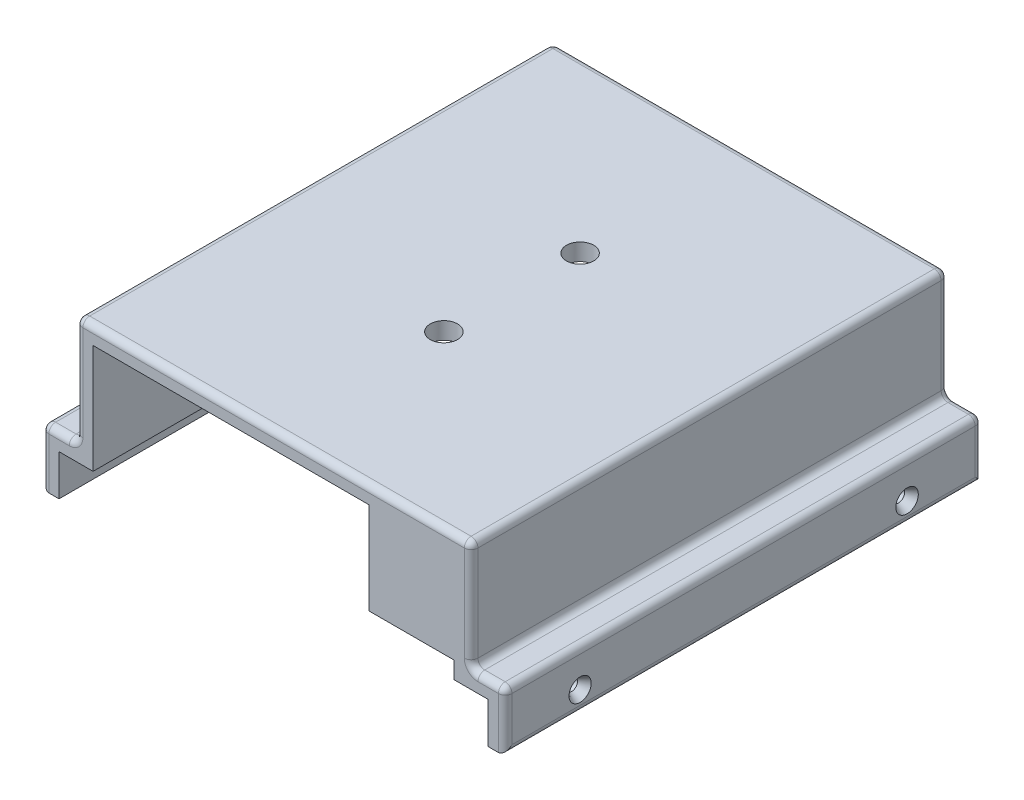
from build123d import *

# Parameters (mm, degrees)
BOSS_EXTRUDE1_DEPTH   = 140
SKETCH4_W             = 25
SKETCH4_H             = 27
BOSS_EXTRUDE2_DEPTH   = 5
SKETCH5_W             = 25
SKETCH5_H             = 27
BOSS_EXTRUDE3_DEPTH   = 5
FILLET1_R             = 2
SKETCH6_R             = 1.75
SKETCH6_R_2           = 1.8
CUT_EXTRUDE1_DEPTH    = 137
CHAMFER1_SIZE         = 1.5
CHAMFER1_SIZE2        = 2.5
CHAMFER2_SIZE         = 2.5
CHAMFER2_SIZE2        = 1.5
CHAMFER2_PART_2_SIZE  = 2.5
CHAMFER2_PART_2_SIZE2 = 1.5
SKETCH8_R             = 4
CUT_EXTRUDE2_DEPTH    = 50


with BuildPart() as part:
    # Sketch3 → Boss-Extrude1 (new body)
    with BuildSketch(Plane.XY):
        Polygon((-58, 0), (58, 0), (58, -32), (68, -32), (68, -49), (63, -49), (63, -37), (53, -37), (53, -5), (-53, -5), (-53, -37), (-63, -37), (-63, -49), (-68, -49), (-68, -32), (-58, -32), align=None)
    extrude(amount=-BOSS_EXTRUDE1_DEPTH)

    # Sketch4 → Boss-Extrude2 (add)
    with BuildSketch(Plane.XY):
        with Locations((40.5, -18.5)):
            Rectangle(SKETCH4_W, SKETCH4_H)
    extrude(amount=-BOSS_EXTRUDE2_DEPTH)

    # Sketch5 → Boss-Extrude3 (add)
    with BuildSketch(Plane(origin=(0, 0, -140), x_dir=(-1, 0, 0), z_dir=(0, 0, -1))):
        with Locations((40.5, -18.5)):
            Rectangle(SKETCH5_W, SKETCH5_H)
    extrude(amount=-BOSS_EXTRUDE3_DEPTH)

    # Fillet1
    fillet1_edges = [part.edges().sort_by_distance(p)[0] for p in [
        (-58, -16, -140),
        (63, -32, 0),
        (68, -40.5, 0),
        (-63, -32, -140),
        (-68, -40.5, 0),
        (-63, -32, 0),
        (-68, -40.5, -140),
        (-58, -16, 0),
        (0, 0, 0),
        (58, -16, 0),
        (58, -32, -70),
        (68, -32, -70),
        (68, -49, -70),
        (-68, -49, -70),
        (-68, -32, -70),
        (-58, -32, -70),
        (-58, 0, -70),
        (58, 0, -70),
        (58, -16, -140),
        (68, -40.5, -140),
        (63, -32, -140),
        (0, 0, -140),
    ]]
    fillet(fillet1_edges, radius=FILLET1_R)

    # Sketch6 → Cut-Extrude1 (cut, through all)
    with BuildSketch(Plane(origin=(68, 0, 0), x_dir=(0, 0, -1), z_dir=(1, 0, 0))):
        with Locations((22, -43)):
            Circle(SKETCH6_R)
        with Locations((118, -43)):
            Circle(SKETCH6_R_2)
    extrude(amount=-CUT_EXTRUDE1_DEPTH, mode=Mode.SUBTRACT)

    # Chamfer1
    chamfer1_edges = [part.edges().sort_by_distance(p)[0] for p in [
        (68, -43, -20.25),
        (68, -43, -116.2),
    ]]
    chamfer1_side = [part.faces().sort_by_distance(p)[0] for p in [
        (68, -40.471685324, -69.984689184),
    ]]
    chamfer(chamfer1_edges, length=CHAMFER1_SIZE, length2=CHAMFER1_SIZE2, reference=chamfer1_side[0])

    # Chamfer2
    chamfer2_edges = [part.edges().sort_by_distance(p)[0] for p in [
        (-68, -43, -20.25),
    ]]
    chamfer2_side = [part.faces().sort_by_distance(p)[0] for p in [
        (-65.5, -43, -20.25),
    ]]
    chamfer(chamfer2_edges, length=CHAMFER2_SIZE, length2=CHAMFER2_SIZE2, reference=chamfer2_side[0])

    # Chamfer2 part 2
    chamfer2_part_2_edges = [part.edges().sort_by_distance(p)[0] for p in [
        (-68, -43, -116.2),
    ]]
    chamfer2_part_2_side = [part.faces().sort_by_distance(p)[0] for p in [
        (-65.5, -43, -116.2),
    ]]
    chamfer(chamfer2_part_2_edges, length=CHAMFER2_PART_2_SIZE, length2=CHAMFER2_PART_2_SIZE2, reference=chamfer2_part_2_side[0])

    # Sketch8 → Cut-Extrude2 (cut, through all)
    with BuildSketch(Plane(origin=(0, 0, 0), x_dir=(1, 0, 0), z_dir=(0, 1, 0))):
        with Locations((0, 90)):
            Circle(SKETCH8_R)
        with Locations((0, 50)):
            Circle(SKETCH8_R)
    extrude(amount=-CUT_EXTRUDE2_DEPTH, mode=Mode.SUBTRACT)


solid = part.part
